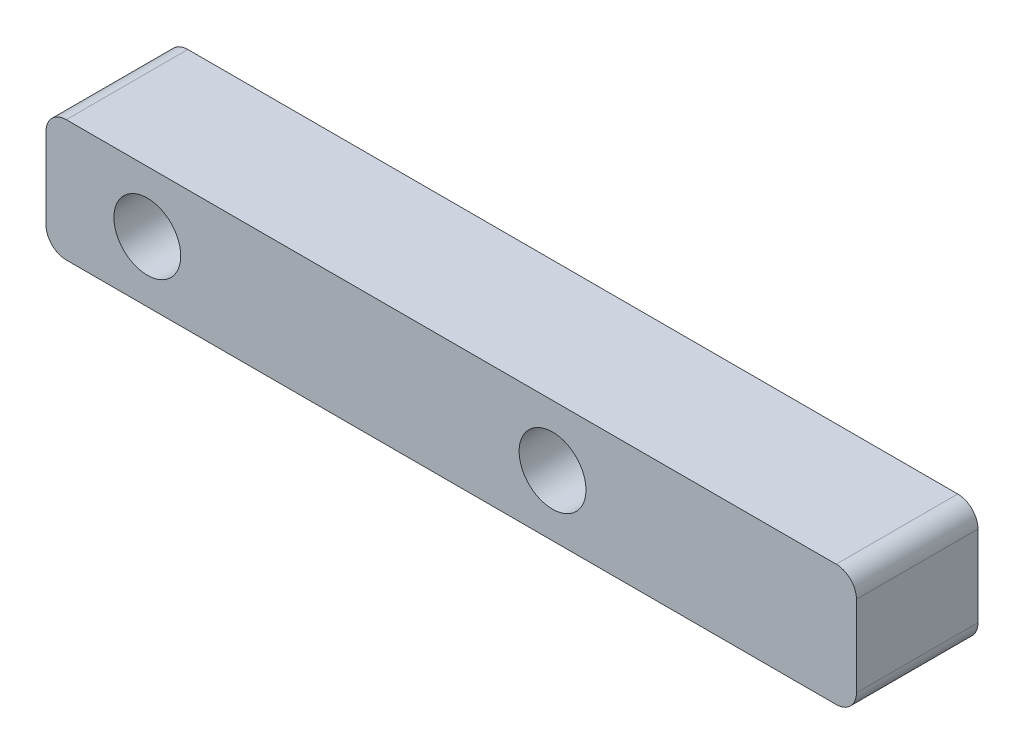
from build123d import *

# Parameters (mm, degrees)
SKETCH_1_W          = 40
SKETCH_1_H          = 6
EXTRUDE_1_DEPTH     = 6
SKETCH_2_R          = 1.65
CUT_EXTRUDE_1_DEPTH = 6
FILLET_1_R          = 1


with BuildPart() as part:
    # 草图1 → 凸台-拉伸1 (new body)
    with BuildSketch(Plane.XY):
        Rectangle(SKETCH_1_W, SKETCH_1_H)
    extrude(amount=EXTRUDE_1_DEPTH)

    # 草图2 → 切除-拉伸1 (cut)
    with BuildSketch(Plane.XY.offset(6)):
        with Locations((5, 0)):
            Circle(SKETCH_2_R)
        with Locations((-15, 0)):
            Circle(SKETCH_2_R)
    extrude(amount=-CUT_EXTRUDE_1_DEPTH, mode=Mode.SUBTRACT)

    # 圆角1
    fillet_1_edges = [part.edges().sort_by_distance(p)[0] for p in [
        (20, -3, 3),
        (-20, -3, 3),
        (-20, 3, 3),
        (20, 3, 3),
    ]]
    fillet(fillet_1_edges, radius=FILLET_1_R)


solid = part.part
